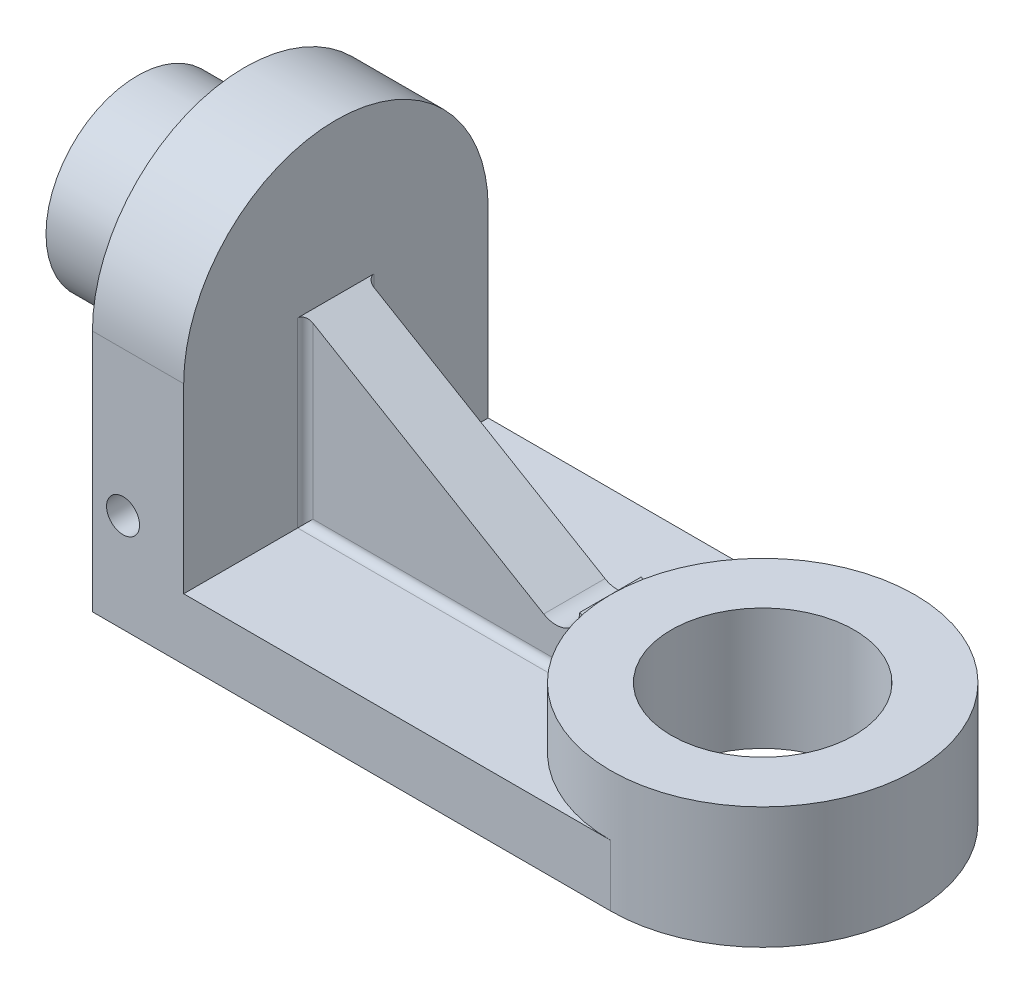
from build123d import *

# Parameters (mm, degrees)
BOSS_EXTRUDE1_DEPTH     = 6.4
SKETCH1_3_R             = 15.9
SKETCH1_3_R_2           = 9.55
BOSS_EXTRUDE2_DEPTH     = 12.7
SKETCH1_4_W             = 9.53
SKETCH1_4_H             = 31.8
BOSS_EXTRUDE3_DEPTH     = 25.4
RIB1_REACH              = 63.845
SKETCH6_WALL_W          = 157.046570884
SKETCH6_WALL_H          = 6.4
CUT_EXTRUDE1_DEPTH      = 62.844805764
CUT_EXTRUDE1_DEPTH_BACK = 62.844805764
BOSS_EXTRUDE10_DEPTH    = 9.53
SKETCH9_R               = 9.55
BOSS_EXTRUDE11_DEPTH    = 11.2
SKETCH10_W              = 22.2
SKETCH10_H              = 7.9
CUT_EXTRUDE2_DEPTH      = 8
SKETCH11_R              = 1.725
CUT_EXTRUDE3_DEPTH      = 84.552498467
FILLET1_R               = 0.8


with BuildPart() as part:
    # Sketch1 → Boss-Extrude1 (new body)
    with BuildSketch(Plane(origin=(0, 0, 0), x_dir=(1, 0, 0), z_dir=(0, 1, 0))):
        with BuildLine():
            ThreePointArc((0, -15.9), (-15.9, 0), (0, 15.9))
            Line((0, 15.9), (-44.57, 15.9))
            Line((-44.57, 15.9), (-44.57, -15.9))
            Line((-44.57, -15.9), (0, -15.9))
        make_face()
    extrude(amount=BOSS_EXTRUDE1_DEPTH)

    # Sketch1_3 → Boss-Extrude2 (add)
    with BuildSketch(Plane(origin=(0, 0, 0), x_dir=(1, 0, 0), z_dir=(0, 1, 0))):
        with Locations(Location((0, 0, 0), (0, 0, 270))):
            Circle(SKETCH1_3_R)
        with Locations(Location((0, 0, 0), (0, 0, 270))):
            Circle(SKETCH1_3_R_2, mode=Mode.SUBTRACT)
    extrude(amount=BOSS_EXTRUDE2_DEPTH)

    # Sketch1_4 → Boss-Extrude3 (add)
    with BuildSketch(Plane(origin=(0, 0, 0), x_dir=(1, 0, 0), z_dir=(0, 1, 0))):
        with Locations((-49.335, 0)):
            Rectangle(SKETCH1_4_W, SKETCH1_4_H)
    extrude(amount=BOSS_EXTRUDE3_DEPTH)

    # Sketch6 wall → Rib1 (add, up to next)
    with BuildSketch(Plane(origin=(-30.235, 19.05, 0), x_dir=(-0.914310589726, 0.405013759662, 0), z_dir=(-0.405013759662, -0.914310589726, 0)), mode=Mode.PRIVATE) as rib1_sk1:
        Rectangle(SKETCH6_WALL_W, SKETCH6_WALL_H)
    rib1_tool1 = extrude(rib1_sk1.sketch, amount=RIB1_REACH, mode=Mode.PRIVATE) - part.part
    add(rib1_tool1.solids().sort_by_distance((-30.235, 19.05, 0))[0])

    # Sketch7 → Cut-Extrude1 (cut, two sides)
    with BuildSketch(Plane.XY) as cut_extrude1_sk:
        with BuildLine():
            Line((-44.57, 25.4), (-19.669441159, 10.673850552))
            ThreePointArc((-19.669441159, 10.673850552), (-17.213195922, 10.623662856), (-15.9, 12.7))
            Line((-15.9, 12.7), (-44.57, 25.4))
        make_face()
    extrude(amount=CUT_EXTRUDE1_DEPTH, mode=Mode.SUBTRACT)
    extrude(cut_extrude1_sk.sketch, amount=-CUT_EXTRUDE1_DEPTH_BACK, mode=Mode.SUBTRACT)

    # Sketch8 → Boss-Extrude10 (add)
    with BuildSketch(Plane(origin=(-44.57, 0, 0), x_dir=(0, 0, -1), z_dir=(1, 0, 0))):
        with BuildLine():
            Line((-15.9, 25.4), (15.9, 25.4))
            ThreePointArc((15.9, 25.4), (0, 41.3), (-15.9, 25.4))
        make_face()
    extrude(amount=-BOSS_EXTRUDE10_DEPTH)

    # Sketch9 → Boss-Extrude11 (add)
    with BuildSketch(Plane.ZY.offset(54.1)):
        with Locations((0, 25.4)):
            Circle(SKETCH9_R)
    extrude(amount=BOSS_EXTRUDE11_DEPTH)

    # Sketch10 → Cut-Extrude2 (cut)
    with BuildSketch(Plane.ZY.offset(54.1)):
        with Locations((0, 10.25)):
            Rectangle(SKETCH10_W, SKETCH10_H)
    extrude(amount=-CUT_EXTRUDE2_DEPTH, mode=Mode.SUBTRACT)

    # Sketch11 → Cut-Extrude3 (cut, through all)
    with BuildSketch(Plane.XY.offset(15.9)):
        with Locations((-50.9, 10.3)):
            Circle(SKETCH11_R)
    extrude(amount=-CUT_EXTRUDE3_DEPTH, mode=Mode.SUBTRACT)

    # Fillet1
    fillet1_edges = [part.edges().sort_by_distance(p)[0] for p in [
        (-46.1, 10.25, -11.1),
        (-50.1, 6.3, -11.1),
        (-46.1, 14.2, 0),
        (-50.1, 14.2, -11.1),
        (-46.1, 10.25, 11.1),
        (-50.1, 14.2, 11.1),
        (-46.1, 6.3, 0),
        (-50.1, 6.3, 11.1),
        (-44.57, 15.9, 3.2),
        (-30.072329452, 6.4, 3.2),
        (-44.57, 15.9, -3.2),
        (-30.072329452, 6.4, -3.2),
    ]]
    fillet(fillet1_edges, radius=FILLET1_R)


solid = part.part
